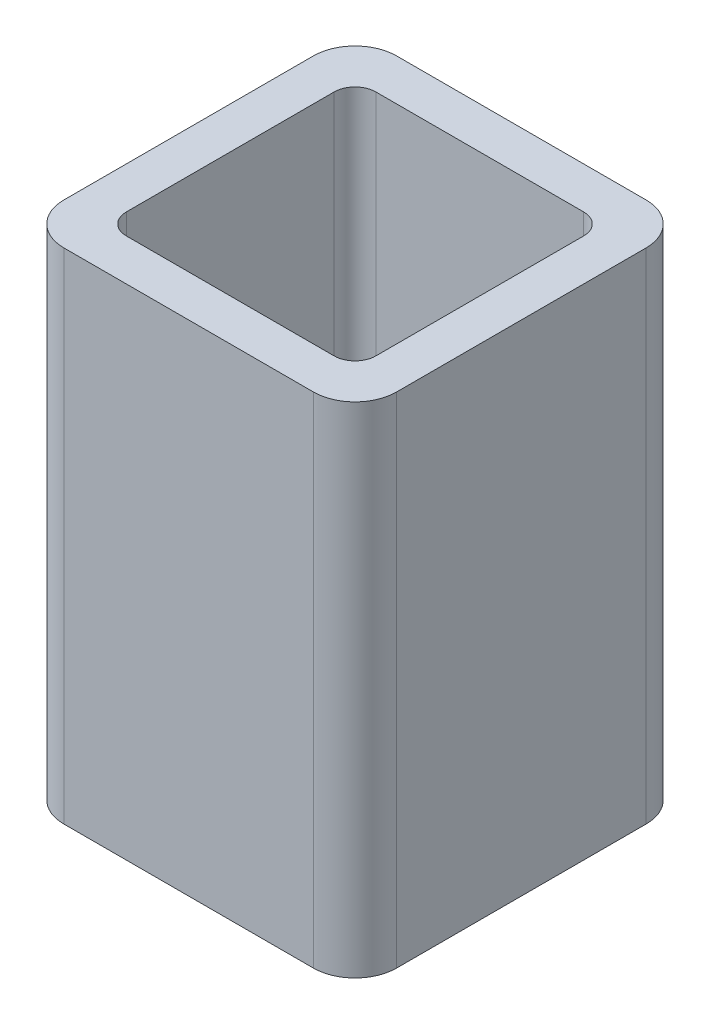
from build123d import *

# Parameters (mm, degrees)
BOSS_EXTRUDE1_DEPTH = 60


with BuildPart() as part:
    # Sketch1 → Boss-Extrude1 (new body, symmetric)
    with BuildSketch(Plane(origin=(0, 0, 0), x_dir=(1, 0, 0), z_dir=(0, 1, 0))):
        with BuildLine():
            Line((-30, -40), (30, -40))
            ThreePointArc((30, -40), (37.071067812, -37.071067812), (40, -30))
            Line((40, -30), (40, 30))
            ThreePointArc((40, 30), (37.071067812, 37.071067812), (30, 40))
            Line((30, 40), (-30, 40))
            ThreePointArc((-30, 40), (-37.071067812, 37.071067812), (-40, 30))
            Line((-40, 30), (-40, -30))
            ThreePointArc((-40, -30), (-37.071067812, -37.071067812), (-30, -40))
        make_face()
        with BuildLine():
            Line((-25, 30), (25, 30))
            ThreePointArc((25, 30), (28.535533906, 28.535533906), (30, 25))
            Line((30, 25), (30, -25))
            ThreePointArc((30, -25), (28.535533906, -28.535533906), (25, -30))
            Line((25, -30), (-25, -30))
            ThreePointArc((-25, -30), (-28.535533906, -28.535533906), (-30, -25))
            Line((-30, -25), (-30, 25))
            ThreePointArc((-30, 25), (-28.535533906, 28.535533906), (-25, 30))
        make_face(mode=Mode.SUBTRACT)
    extrude(amount=BOSS_EXTRUDE1_DEPTH, both=True)


solid = part.part
